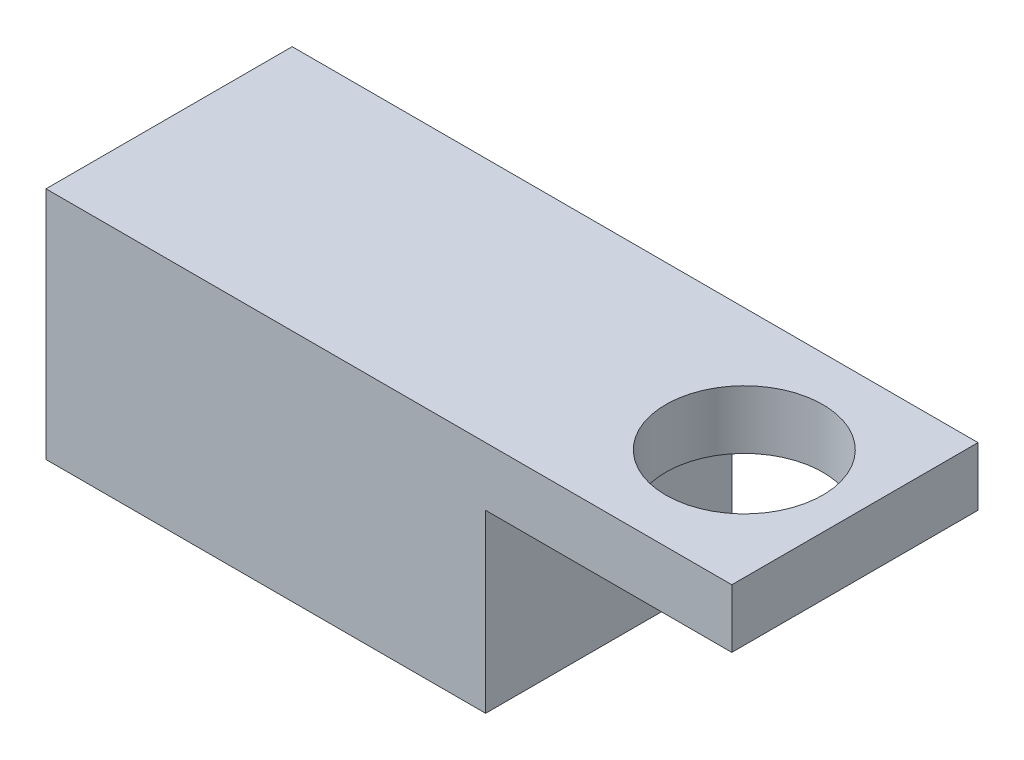
from build123d import *

# Parameters (mm, degrees)
SKETCH1_W                = 29.718
SKETCH1_H                = 10.668
BOSS_EXTRUDE1_DEPTH      = 10.16
SKETCH2_W                = 10.668
SKETCH2_H                = 10.668
CUT_EXTRUDE1_DEPTH       = 7.62
M6_CLEARANCE_HOLE1_D     = 6.8032
M6_CLEARANCE_HOLE1_DEPTH = 32.4993
M6_CLEARANCE_HOLE1_TIP   = 2.043887482


with BuildPart() as part:
    # Sketch1 → Boss-Extrude1 (new body)
    with BuildSketch(Plane(origin=(0, 0, 0), x_dir=(1, 0, 0), z_dir=(0, 1, 0))):
        Rectangle(SKETCH1_W, SKETCH1_H)
    extrude(amount=BOSS_EXTRUDE1_DEPTH)

    # Sketch2 → Cut-Extrude1 (cut)
    with BuildSketch(Plane(origin=(0, 0, 0), x_dir=(-1, 0, 0), z_dir=(0, -1, 0))):
        with Locations((-9.525, 0)):
            Rectangle(SKETCH2_W, SKETCH2_H)
    extrude(amount=-CUT_EXTRUDE1_DEPTH, mode=Mode.SUBTRACT)

    # M6 Clearance Hole1
    with Locations(Plane(origin=(0, 10.16, 0), x_dir=(1, 0, 0), z_dir=(0, 1, 0))):
        with Locations((10.06602, 0)):
            Hole(M6_CLEARANCE_HOLE1_D / 2, depth=M6_CLEARANCE_HOLE1_DEPTH)
            with Locations((0, 0, -(M6_CLEARANCE_HOLE1_DEPTH + M6_CLEARANCE_HOLE1_TIP / 2))):  # 118° drill point
                Cone(0, M6_CLEARANCE_HOLE1_D / 2, M6_CLEARANCE_HOLE1_TIP, mode=Mode.SUBTRACT)


solid = part.part
